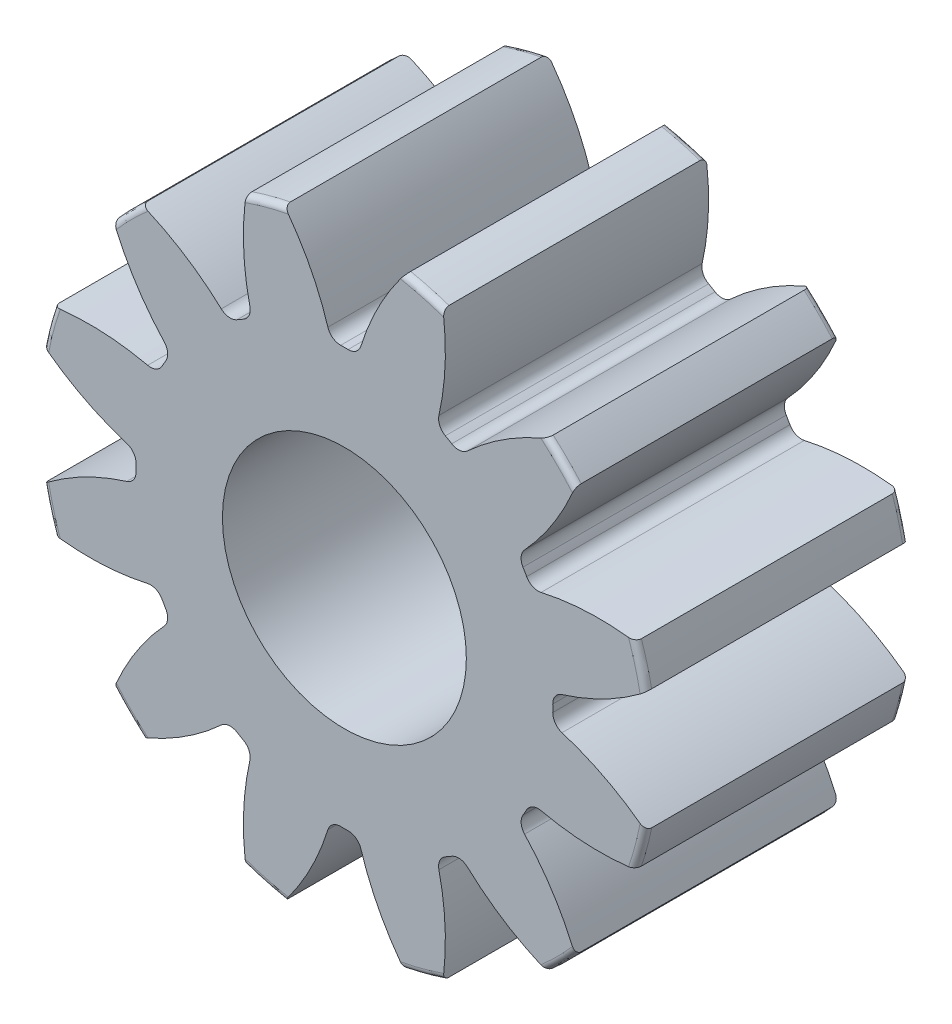
from build123d import *

# Parameters (mm, degrees)
FILLET2_R          = 0.07
CUT_EXTRUDE2_DEPTH = 4
CIRPATTERN1_COUNT  = 12
SKETCH8_R          = 3.5
CUT_EXTRUDE3_DEPTH = 4
SKETCH9_R          = 1.39
CUT_EXTRUDE4_DEPTH = 4.0000001


with BuildPart() as part:
    # Sketch4 → Revolve1 (revolve)
    with BuildSketch(Plane(origin=(0, 0, 0), x_dir=(0, 0, -1), z_dir=(1, 0, 0))):
        Polygon((-7, 1), (-7, 2.25), (-3, 2.25), (-3, 3.5), (0, 3.5), (0, 1), align=None)
    revolve(axis=Axis((0, 0, 3), (0, 0, 1)))

    # Fillet2
    fillet2_edges = [part.edges().sort_by_distance(p)[0] for p in [
        (0, -3.5, 0),
        (0, -3.5, 3),
        (0, -2.25, 3),
        (0, -2.25, 7),
    ]]
    fillet(fillet2_edges, radius=FILLET2_R)

    # Sketch7 → Cut-Extrude2 (cut, through all)
    with BuildSketch(Plane.XY.offset(3)):
        with BuildLine():
            ThreePointArc((-0.042070551, 2.374627354), (0, 2.375), (0.042070551, 2.374627354))
            ThreePointArc((0.042070551, 2.374627354), (0.13259254, 2.40302909), (0.187970292, 2.480062809))
            ThreePointArc((0.187970292, 2.480062809), (0.393796454, 2.978587459), (0.685558819, 3.432201787))
            ThreePointArc((0.685558819, 3.432201787), (0, 3.5), (-0.685558819, 3.432201787))
            ThreePointArc((-0.685558819, 3.432201787), (-0.393796454, 2.978587459), (-0.187970292, 2.480062809))
            ThreePointArc((-0.187970292, 2.480062809), (-0.13259254, 2.40302909), (-0.042070551, 2.374627354))
        make_face()
    cut_extrude2 = extrude(amount=-CUT_EXTRUDE2_DEPTH, mode=Mode.SUBTRACT)

    # CirPattern1: Cut-Extrude2 ×12 about axis
    cirpattern1_axis = Axis((0, 0, 0), (0, 0, 1))
    for i in range(1, CIRPATTERN1_COUNT):
        add(cut_extrude2.rotate(cirpattern1_axis, i * 360 / CIRPATTERN1_COUNT), mode=Mode.SUBTRACT)

    # Sketch8 → Cut-Extrude3 (cut)
    with BuildSketch(Plane.XY.offset(7)):
        Circle(SKETCH8_R)
    extrude(amount=-CUT_EXTRUDE3_DEPTH, mode=Mode.SUBTRACT)

    # Sketch9 → Cut-Extrude4 (cut, through all)
    with BuildSketch(Plane.XY.offset(3)):
        Circle(SKETCH9_R)
    extrude(amount=-CUT_EXTRUDE4_DEPTH, mode=Mode.SUBTRACT)


solid = part.part
